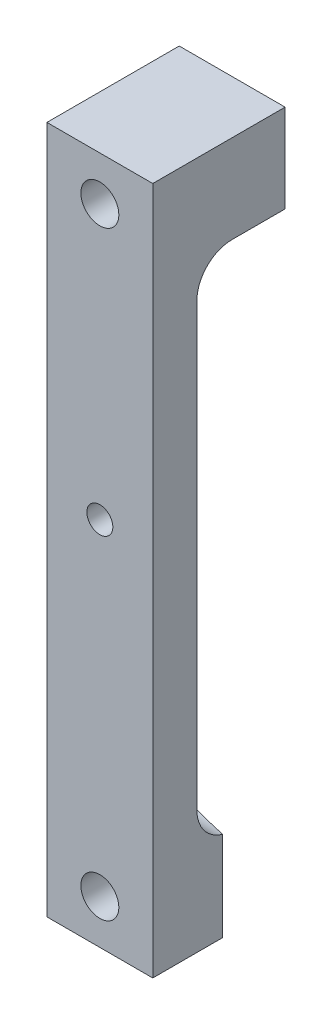
from build123d import *

# Parameters (mm, degrees)
EXTRUDE1_DEPTH        = 5
SKETCH3_R             = 1.4732
CUT_EXTRUDE2_DEPTH    = 6
SKETCH4_W             = 12
SKETCH4_H             = 10
EXTRUDE2_DEPTH        = 10
FILLET1_R             = 4
CUT_EXTRUDE3_DEPTH    = 39
F_8_CLEARANCE_HOLE1_D = 4.3053


with BuildPart() as part:
    # Sketch1 → Extrude1 (new body)
    with BuildSketch(Plane.XY):
        Polygon((0, 39), (0, -39), (12, -39), (12, 0), (12, 39), align=None)
    extrude(amount=EXTRUDE1_DEPTH)

    # Sketch3 → Cut-Extrude2 (cut, through all)
    with BuildSketch(Plane.XY.offset(5)):
        with Locations((6, 3)):
            Circle(SKETCH3_R)
    extrude(amount=-CUT_EXTRUDE2_DEPTH, mode=Mode.SUBTRACT)

    # Sketch4 → Extrude2 (add)
    with BuildSketch(Plane(origin=(0, 0, 0), x_dir=(-1, 0, 0), z_dir=(0, 0, -1))):
        with Locations((-6, 34)):
            Rectangle(SKETCH4_W, SKETCH4_H)
        with Locations((-6, -34)):
            Rectangle(SKETCH4_W, SKETCH4_H)
    extrude(amount=EXTRUDE2_DEPTH)

    # Fillet1
    fillet1_edges = [part.edges().sort_by_distance(p)[0] for p in [
        (6, -29, 0),
        (6, 29, 0),
    ]]
    fillet(fillet1_edges, radius=FILLET1_R)

    # Sketch5 → Cut-Extrude3 (cut)
    with BuildSketch(Plane(origin=(0, 0, 0), x_dir=(1, 0, 0), z_dir=(0, 1, 0))):
        Polygon((0, 10), (0, 6.192), (12, 2.931672159), (12, 8.784609691), (12, 10), align=None)
    extrude(amount=-CUT_EXTRUDE3_DEPTH, mode=Mode.SUBTRACT)

    # #8 Clearance Hole1 (through all)
    with Locations(Plane(origin=(6, 34, 5), x_dir=(1, 0, 0), z_dir=(0, 0, 1))):
        with Locations((0, 0), (0, -68)):
            Hole(F_8_CLEARANCE_HOLE1_D / 2)


solid = part.part
